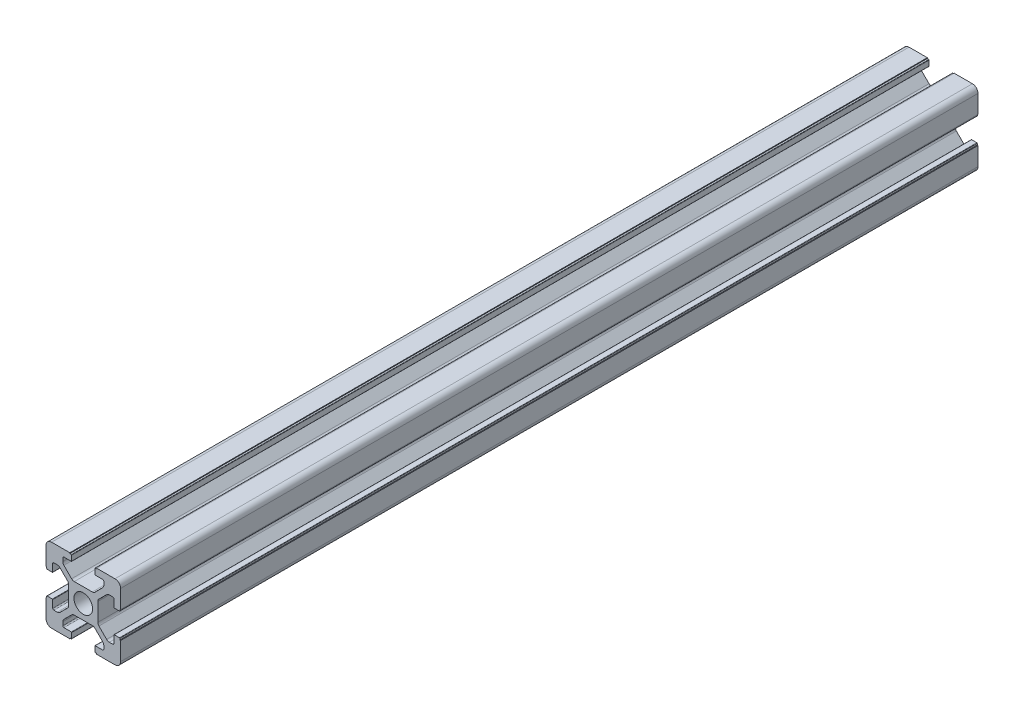
from build123d import *

# Parameters (mm, degrees)
SKETCH_1_R      = 2.5
EXTRUDE_1_DEPTH = 230
FILLET_1_R      = 1.5


with BuildPart() as part:
    # 草图1 → 凸台-拉伸1 (new body)
    with BuildSketch(Plane.XY):
        with BuildLine():
            Line((20, 13.6), (20, 20))
            Line((20, 20), (13.6, 20))
            Line((13.6, 20), (13.6, 19.8))
            Line((13.6, 19.8), (13.2, 19.8))
            ThreePointArc((13.2, 19.8), (13.129289322, 19.770710678), (13.1, 19.7))
            Line((13.1, 19.7), (13.1, 18.3))
            ThreePointArc((13.1, 18.3), (13.129289322, 18.229289322), (13.2, 18.2))
            Line((13.2, 18.2), (15.2, 18.2))
            ThreePointArc((15.2, 18.2), (15.412132034, 18.112132034), (15.5, 17.9))
            Line((15.5, 17.9), (15.5, 16.974873734))
            ThreePointArc((15.5, 16.974873734), (15.423879533, 16.592190302), (15.207106781, 16.267766953))
            Line((15.207106781, 16.267766953), (13.132233047, 14.192893219))
            ThreePointArc((13.132233047, 14.192893219), (12.807809698, 13.976120467), (12.425126266, 13.9))
            Line((12.425126266, 13.9), (7.574873734, 13.9))
            ThreePointArc((7.574873734, 13.9), (7.192190302, 13.976120467), (6.867766953, 14.192893219))
            Line((6.867766953, 14.192893219), (4.792893219, 16.267766953))
            ThreePointArc((4.792893219, 16.267766953), (4.576120467, 16.592190302), (4.5, 16.974873734))
            Line((4.5, 16.974873734), (4.5, 17.9))
            ThreePointArc((4.5, 17.9), (4.587867966, 18.112132034), (4.8, 18.2))
            Line((4.8, 18.2), (6.8, 18.2))
            ThreePointArc((6.8, 18.2), (6.870710678, 18.229289322), (6.9, 18.3))
            Line((6.9, 18.3), (6.9, 19.7))
            ThreePointArc((6.9, 19.7), (6.870710678, 19.770710678), (6.8, 19.8))
            Line((6.8, 19.8), (6.4, 19.8))
            Line((6.4, 19.8), (6.4, 20))
            Line((6.4, 20), (0, 20))
            Line((0, 20), (0, 13.6))
            Line((0, 13.6), (0.2, 13.6))
            Line((0.2, 13.6), (0.2, 13.2))
            ThreePointArc((0.2, 13.2), (0.229289322, 13.129289322), (0.3, 13.1))
            Line((0.3, 13.1), (1.7, 13.1))
            ThreePointArc((1.7, 13.1), (1.770710678, 13.129289322), (1.8, 13.2))
            Line((1.8, 13.2), (1.8, 15.2))
            ThreePointArc((1.8, 15.2), (1.887867966, 15.412132034), (2.1, 15.5))
            Line((2.1, 15.5), (3.025126266, 15.5))
            ThreePointArc((3.025126266, 15.5), (3.407809698, 15.423879533), (3.732233047, 15.207106781))
            Line((3.732233047, 15.207106781), (5.807106781, 13.132233047))
            ThreePointArc((5.807106781, 13.132233047), (6.023879533, 12.807809698), (6.1, 12.425126266))
            Line((6.1, 12.425126266), (6.1, 7.574873734))
            ThreePointArc((6.1, 7.574873734), (6.023879533, 7.192190302), (5.807106781, 6.867766953))
            Line((5.807106781, 6.867766953), (3.732233047, 4.792893219))
            ThreePointArc((3.732233047, 4.792893219), (3.407809698, 4.576120467), (3.025126266, 4.5))
            Line((3.025126266, 4.5), (2.1, 4.5))
            ThreePointArc((2.1, 4.5), (1.887867966, 4.587867966), (1.8, 4.8))
            Line((1.8, 4.8), (1.8, 6.8))
            ThreePointArc((1.8, 6.8), (1.770710678, 6.870710678), (1.7, 6.9))
            Line((1.7, 6.9), (0.3, 6.9))
            ThreePointArc((0.3, 6.9), (0.229289322, 6.870710678), (0.2, 6.8))
            Line((0.2, 6.8), (0.2, 6.4))
            Line((0.2, 6.4), (0, 6.4))
            Line((0, 6.4), (0, 0))
            Line((0, 0), (6.4, 0))
            Line((6.4, 0), (6.4, 0.2))
            Line((6.4, 0.2), (6.8, 0.2))
            ThreePointArc((6.8, 0.2), (6.870710678, 0.229289322), (6.9, 0.3))
            Line((6.9, 0.3), (6.9, 1.7))
            ThreePointArc((6.9, 1.7), (6.870710678, 1.770710678), (6.8, 1.8))
            Line((6.8, 1.8), (4.8, 1.8))
            ThreePointArc((4.8, 1.8), (4.587867966, 1.887867966), (4.5, 2.1))
            Line((4.5, 2.1), (4.5, 3.025126266))
            ThreePointArc((4.5, 3.025126266), (4.576120467, 3.407809698), (4.792893219, 3.732233047))
            Line((4.792893219, 3.732233047), (6.867766953, 5.807106781))
            ThreePointArc((6.867766953, 5.807106781), (7.192190302, 6.023879533), (7.574873734, 6.1))
            Line((7.574873734, 6.1), (12.425126266, 6.1))
            ThreePointArc((12.425126266, 6.1), (12.807809698, 6.023879533), (13.132233047, 5.807106781))
            Line((13.132233047, 5.807106781), (15.207106781, 3.732233047))
            ThreePointArc((15.207106781, 3.732233047), (15.423879533, 3.407809698), (15.5, 3.025126266))
            Line((15.5, 3.025126266), (15.5, 2.1))
            ThreePointArc((15.5, 2.1), (15.412132034, 1.887867966), (15.2, 1.8))
            Line((15.2, 1.8), (13.2, 1.8))
            ThreePointArc((13.2, 1.8), (13.129289322, 1.770710678), (13.1, 1.7))
            Line((13.1, 1.7), (13.1, 0.3))
            ThreePointArc((13.1, 0.3), (13.129289322, 0.229289322), (13.2, 0.2))
            Line((13.2, 0.2), (13.6, 0.2))
            Line((13.6, 0.2), (13.6, 0))
            Line((13.6, 0), (20, 0))
            Line((20, 0), (20, 6.4))
            Line((20, 6.4), (19.8, 6.4))
            Line((19.8, 6.4), (19.8, 6.8))
            ThreePointArc((19.8, 6.8), (19.770710678, 6.870710678), (19.7, 6.9))
            Line((19.7, 6.9), (18.3, 6.9))
            ThreePointArc((18.3, 6.9), (18.229289322, 6.870710678), (18.2, 6.8))
            Line((18.2, 6.8), (18.2, 4.8))
            ThreePointArc((18.2, 4.8), (18.112132034, 4.587867966), (17.9, 4.5))
            Line((17.9, 4.5), (16.974873734, 4.5))
            ThreePointArc((16.974873734, 4.5), (16.592190302, 4.576120467), (16.267766953, 4.792893219))
            Line((16.267766953, 4.792893219), (14.192893219, 6.867766953))
            ThreePointArc((14.192893219, 6.867766953), (13.976120467, 7.192190302), (13.9, 7.574873734))
            Line((13.9, 7.574873734), (13.9, 12.425126266))
            ThreePointArc((13.9, 12.425126266), (13.976120467, 12.807809698), (14.192893219, 13.132233047))
            Line((14.192893219, 13.132233047), (16.267766953, 15.207106781))
            ThreePointArc((16.267766953, 15.207106781), (16.592190302, 15.423879533), (16.974873734, 15.5))
            Line((16.974873734, 15.5), (17.9, 15.5))
            ThreePointArc((17.9, 15.5), (18.112132034, 15.412132034), (18.2, 15.2))
            Line((18.2, 15.2), (18.2, 13.2))
            ThreePointArc((18.2, 13.2), (18.229289322, 13.129289322), (18.3, 13.1))
            Line((18.3, 13.1), (19.7, 13.1))
            ThreePointArc((19.7, 13.1), (19.770710678, 13.129289322), (19.8, 13.2))
            Line((19.8, 13.2), (19.8, 13.6))
            Line((19.8, 13.6), (20, 13.6))
        make_face()
        with Locations((10, 10)):
            Circle(SKETCH_1_R, mode=Mode.SUBTRACT)
    extrude(amount=EXTRUDE_1_DEPTH)

    # 圆角1
    fillet_1_edges = [part.edges().sort_by_distance(p)[0] for p in [
        (0, 0, 115),
        (0, 20, 115),
        (20, 20, 115),
        (20, 0, 115),
    ]]
    fillet(fillet_1_edges, radius=FILLET_1_R)


solid = part.part
